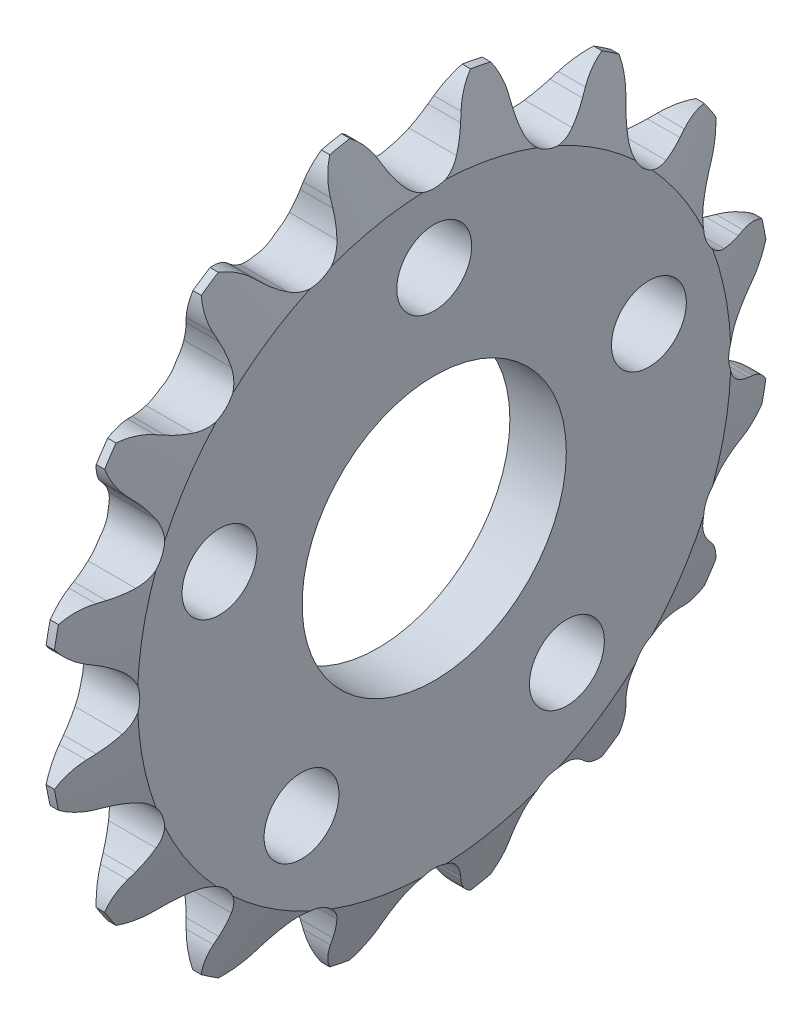
from build123d import *

# Parameters (mm, degrees)
CUT_EXTRUDE1_DEPTH = 26.299301028
CIRPATTERN1_COUNT  = 16
SKETCH4_R          = 6.5405
SKETCH4_R_2        = 1.8542
CUT_EXTRUDE2_DEPTH = 26.06201233


with BuildPart() as part:
    # Sketch2 → Revolve1 (revolve)
    with BuildSketch(Plane.XY):
        Polygon((-0.206375, 17.862013093), (0.206375, 17.862013093), (1.397, 14.687013093), (1.397, 0), (-1.397, 0), (-1.397, 14.687013093), align=None)
    revolve(axis=Axis((-1.397, 0, 0), (1, 0, 0)))

    # Sketch3 → Cut-Extrude1 (cut, symmetric)
    with BuildSketch(Plane(origin=(0, 0, 0), x_dir=(0, 0, -1), z_dir=(1, 0, 0))):
        with BuildLine():
            Line((-2.051408678, 16.490963774), (-1.895951627, 16.145861918))
            ThreePointArc((-1.895951627, 16.145861918), (-1.639424454, 15.660854777), (-1.323740827, 15.212098758))
            ThreePointArc((-1.323740827, 15.212098758), (0, 14.577158093), (1.323740827, 15.212098758))
            ThreePointArc((1.323740827, 15.212098758), (1.639424454, 15.660854777), (1.895951627, 16.145861918))
            Line((1.895951627, 16.145861918), (2.051408678, 16.490963774))
            ThreePointArc((2.051408678, 16.490963774), (2.666228008, 17.353882105), (3.563871438, 17.916791625))
            ThreePointArc((3.563871438, 17.916791625), (0, 18.267802324), (-3.563871438, 17.916791625))
            ThreePointArc((-3.563871438, 17.916791625), (-2.666228008, 17.353882105), (-2.051408678, 16.490963774))
        make_face()
    cut_extrude1 = extrude(amount=CUT_EXTRUDE1_DEPTH, both=True, mode=Mode.SUBTRACT)

    # CirPattern1: Cut-Extrude1 ×16 about axis
    cirpattern1_axis = Axis((-88.99, 0, 0), (1, 0, 0))
    for i in range(1, CIRPATTERN1_COUNT):
        add(cut_extrude1.rotate(cirpattern1_axis, i * 360 / CIRPATTERN1_COUNT), mode=Mode.SUBTRACT)

    # Sketch4 → Cut-Extrude2 (cut, through all)
    with BuildSketch(Plane(origin=(1.397, 0, 0), x_dir=(0, 0, -1), z_dir=(1, 0, 0))):
        Circle(SKETCH4_R)
        with Locations((0, 11.176)):
            Circle(SKETCH4_R_2)
        with Locations((10.629007626, 3.453573929)):
            Circle(SKETCH4_R_2)
        with Locations((6.56908798, -9.041573929)):
            Circle(SKETCH4_R_2)
        with Locations((-6.56908798, -9.041573929)):
            Circle(SKETCH4_R_2)
        with Locations((-10.629007626, 3.453573929)):
            Circle(SKETCH4_R_2)
    extrude(amount=-CUT_EXTRUDE2_DEPTH, mode=Mode.SUBTRACT)


solid = part.part
